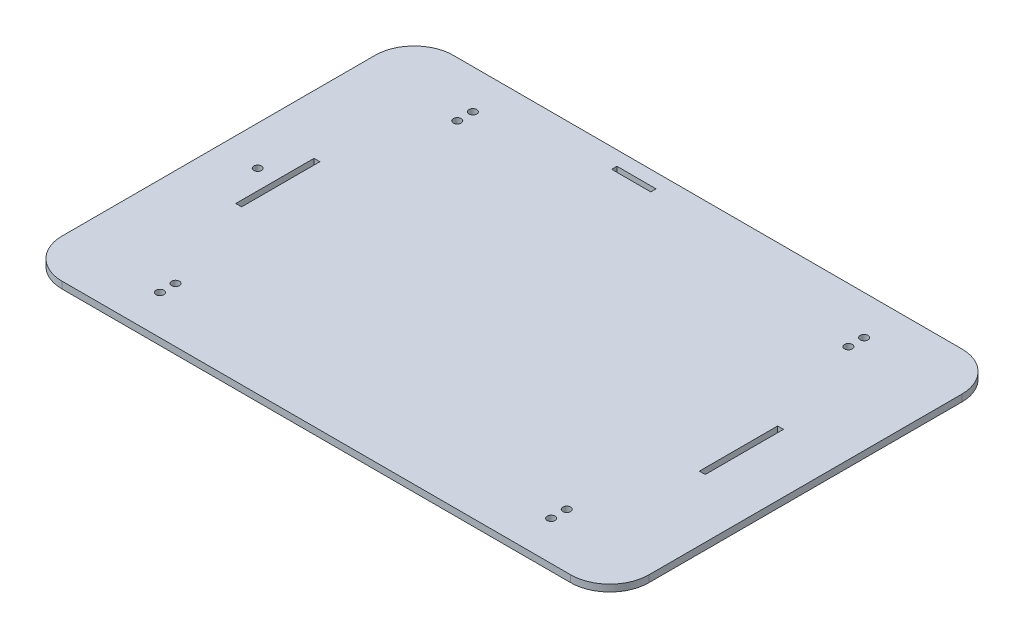
from build123d import *

# Parameters (mm, degrees)
SKETCH1_R           = 2
BOSS_EXTRUDE1_DEPTH = 3.5
SKETCH3_R           = 2
SKETCH3_W           = 3
SKETCH3_H           = 40
SKETCH3_W_2         = 20
SKETCH3_H_2         = 2.698971111
CUT_EXTRUDE2_DEPTH  = 10


with BuildPart() as part:
    # Sketch1 → Boss-Extrude1 (new body)
    with BuildSketch(Plane(origin=(0, 0, 0), x_dir=(1, 0, 0), z_dir=(0, 1, 0))):
        with BuildLine():
            Line((130, -100), (-130, -100))
            ThreePointArc((-130, -100), (-144.142135624, -94.142135624), (-150, -80))
            Line((-150, -80), (-150, 80))
            ThreePointArc((-150, 80), (-144.142135624, 94.142135624), (-130, 100))
            Line((-130, 100), (130, 100))
            ThreePointArc((130, 100), (144.142135624, 94.142135624), (150, 80))
            Line((150, 80), (150, -80))
            ThreePointArc((150, -80), (144.142135624, -94.142135624), (130, -100))
        make_face()
        with Locations((-100, 80)):
            Circle(SKETCH1_R, mode=Mode.SUBTRACT)
        with Locations((100, 80)):
            Circle(SKETCH1_R, mode=Mode.SUBTRACT)
        with Locations((100, -80)):
            Circle(SKETCH1_R, mode=Mode.SUBTRACT)
        with Locations((-100, -80)):
            Circle(SKETCH1_R, mode=Mode.SUBTRACT)
        with Locations((-130, 0)):
            Circle(SKETCH1_R, mode=Mode.SUBTRACT)
    extrude(amount=BOSS_EXTRUDE1_DEPTH)

    # Sketch3 → Cut-Extrude2 (cut)
    with BuildSketch(Plane(origin=(0, 3.5, 0), x_dir=(1, 0, 0), z_dir=(0, 1, 0))):
        with Locations((-100, 72)):
            Circle(SKETCH3_R)
        with Locations((-100, -72)):
            Circle(SKETCH3_R)
        with Locations((100, -72)):
            Circle(SKETCH3_R)
        with Locations((100, 72)):
            Circle(SKETCH3_R)
        with Locations((-118.5, -1.214097356)):
            Rectangle(SKETCH3_W, SKETCH3_H)
        with Locations((118.5, -1.214097356)):
            Rectangle(SKETCH3_W, SKETCH3_H)
        with Locations((-29.050201182, 91.349485555)):
            Rectangle(SKETCH3_W_2, SKETCH3_H_2)
    extrude(amount=-CUT_EXTRUDE2_DEPTH, mode=Mode.SUBTRACT)


solid = part.part
